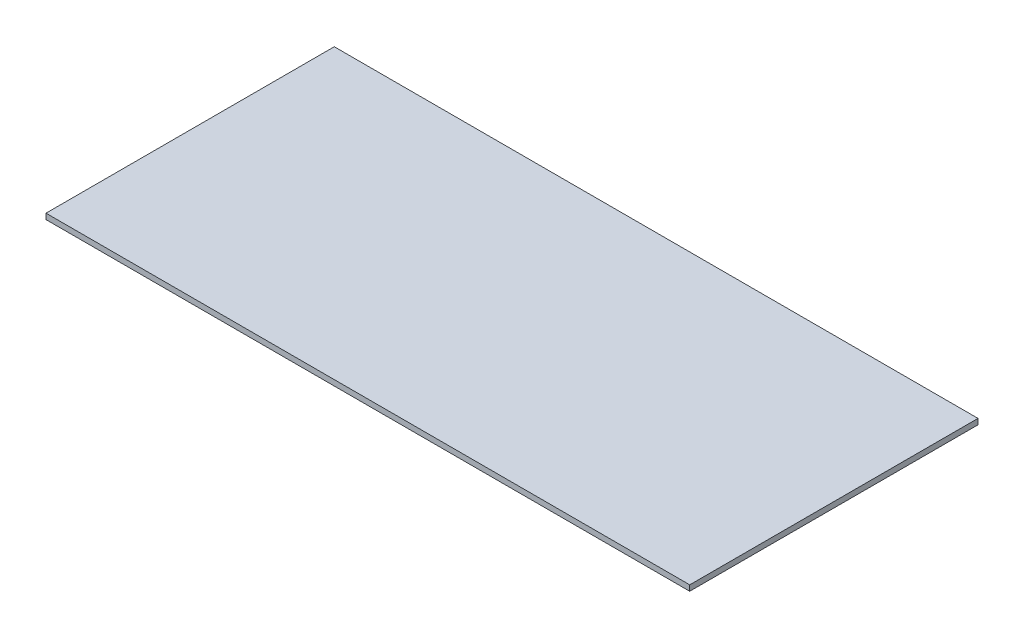
from build123d import *

# Parameters (mm, degrees)
SKETCH1_W           = 230
SKETCH1_H           = 103
BOSS_EXTRUDE1_DEPTH = 2


with BuildPart() as part:
    # Sketch1 → Boss-Extrude1 (new body)
    with BuildSketch(Plane(origin=(0, 0, 0), x_dir=(1, 0, 0), z_dir=(0, 1, 0))):
        Rectangle(SKETCH1_W, SKETCH1_H)
    extrude(amount=BOSS_EXTRUDE1_DEPTH)


solid = part.part
